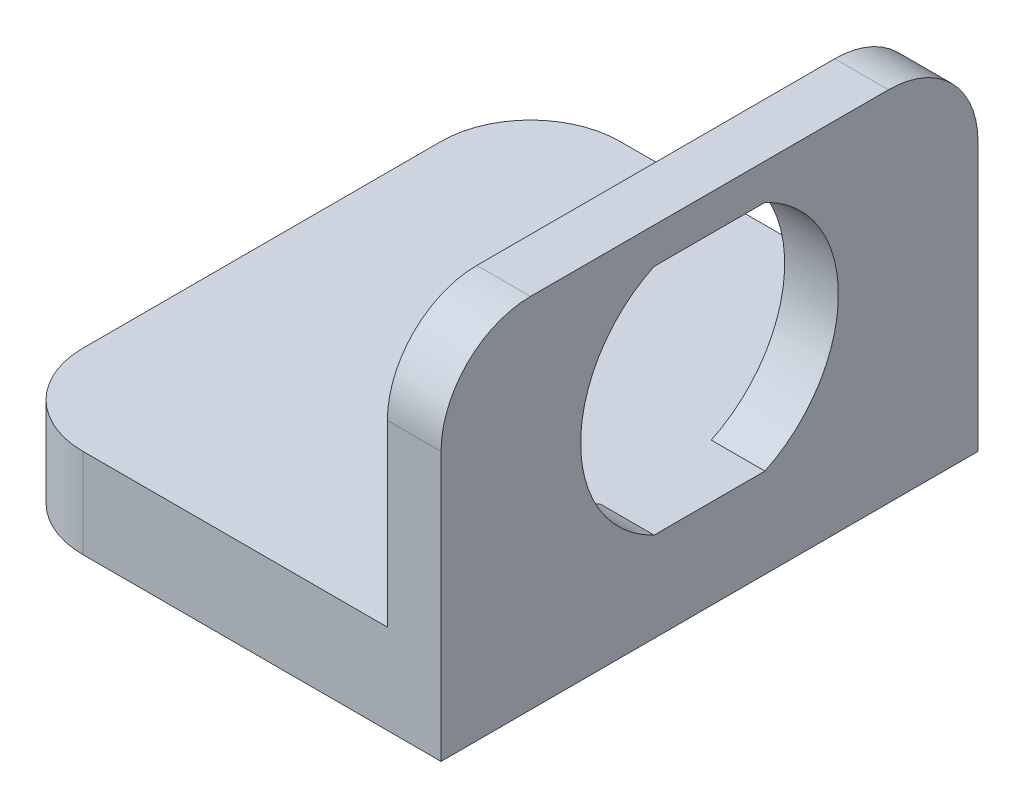
from build123d import *

# Parameters (mm, degrees)
BOSS_EXTRUDE1_DEPTH     = 38.1
F_1_4_20_TAPPED_HOLE1_D = 5.1054
CUT_EXTRUDE1_DEPTH      = 32.75
FILLET1_R               = 6.35


with BuildPart() as part:
    # Sketch1 → Boss-Extrude1 (new body)
    with BuildSketch(Plane.XY):
        Polygon((0, 0), (0, 25.4), (-3.81, 25.4), (-3.81, 6.35), (-31.75, 6.35), (-31.75, 0), align=None)
    extrude(amount=BOSS_EXTRUDE1_DEPTH)

    # 1/4-20 Tapped Hole1 (through all)
    with Locations(Plane(origin=(0, 6.35, 0), x_dir=(1, 0, 0), z_dir=(0, 1, 0))):
        with Locations((-16.51, -19.05)):
            Hole(F_1_4_20_TAPPED_HOLE1_D / 2)

    # Sketch4 → Cut-Extrude1 (cut, through all)
    with BuildSketch(Plane(origin=(0, 0, 0), x_dir=(0, 0, -1), z_dir=(1, 0, 0))):
        with BuildLine():
            Line((-22.982901092, 22.86), (-15.117098908, 22.86))
            ThreePointArc((-15.117098908, 22.86), (-9.906, 14.605), (-15.117098908, 6.35))
            Line((-15.117098908, 6.35), (-22.982901092, 6.35))
            ThreePointArc((-22.982901092, 6.35), (-28.194, 14.605), (-22.982901092, 22.86))
        make_face()
    extrude(amount=-CUT_EXTRUDE1_DEPTH, mode=Mode.SUBTRACT)

    # Fillet1
    fillet1_edges = [part.edges().sort_by_distance(p)[0] for p in [
        (-1.905, 25.4, 38.1),
        (-31.75, 3.175, 38.1),
        (-31.75, 3.175, 0),
        (-1.905, 25.4, 0),
    ]]
    fillet(fillet1_edges, radius=FILLET1_R)


solid = part.part
